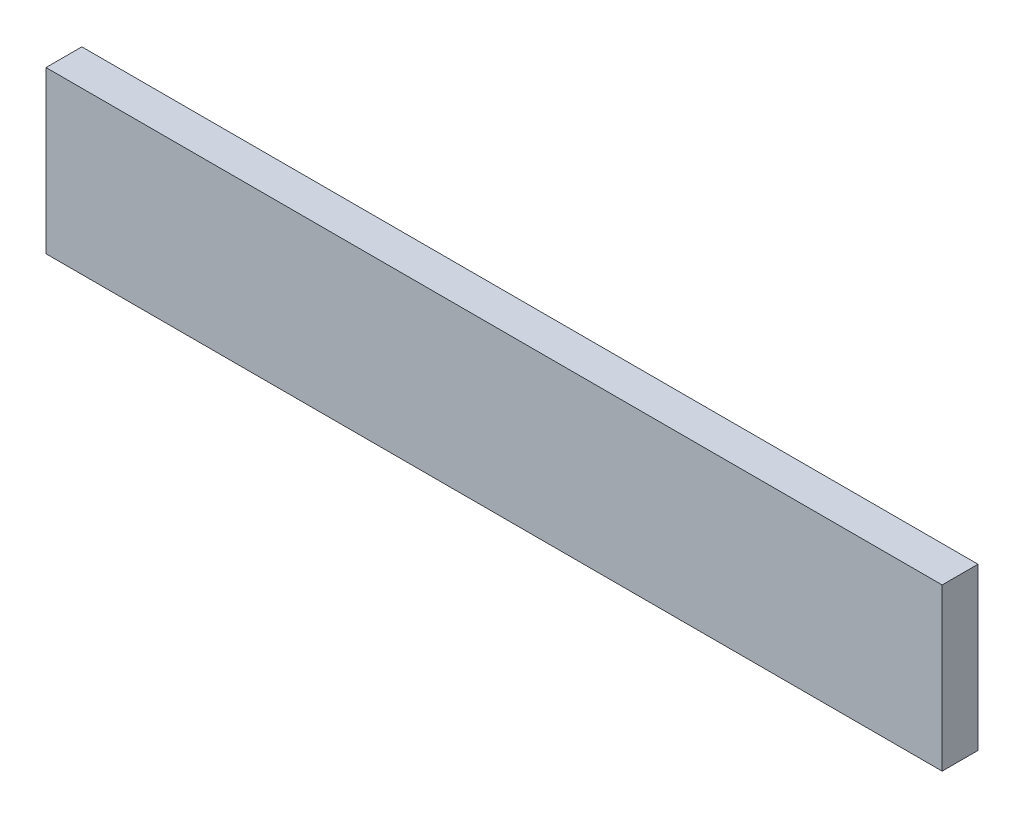
from build123d import *

# Parameters (mm, degrees)
SKETCH1_W           = 250
SKETCH1_H           = 45
BOSS_EXTRUDE1_DEPTH = 10


with BuildPart() as part:
    # Sketch1 → Boss-Extrude1 (new body)
    with BuildSketch(Plane.XY):
        with Locations((-125, 22.5)):
            Rectangle(SKETCH1_W, SKETCH1_H)
    extrude(amount=BOSS_EXTRUDE1_DEPTH)


solid = part.part
